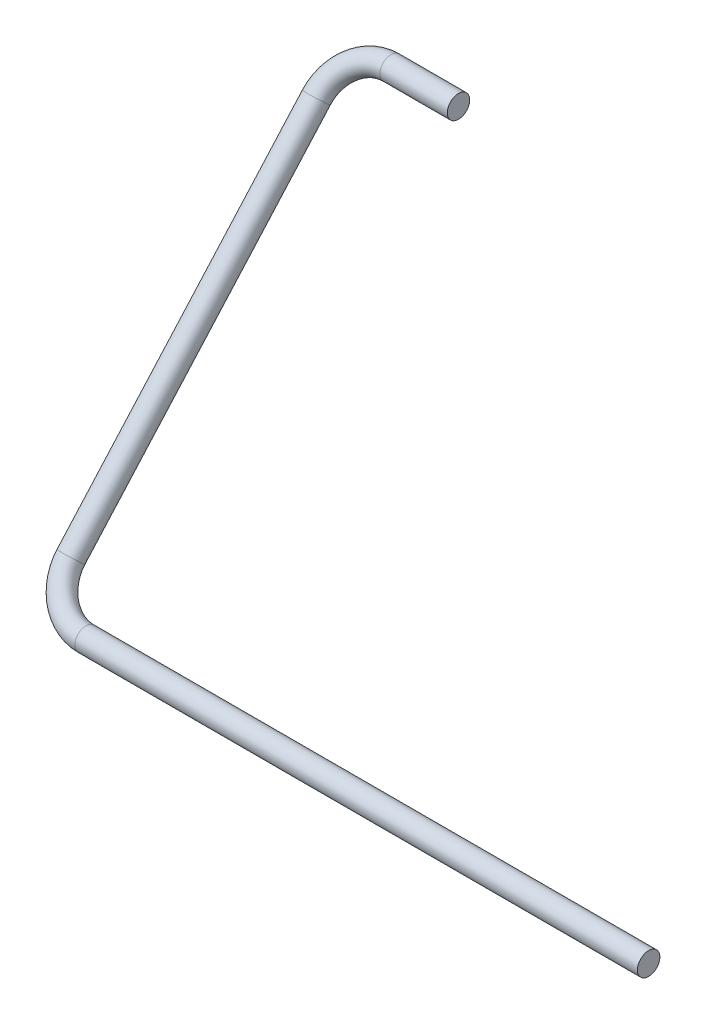
from build123d import *

# Parameters (mm, degrees)
SWEEP1_PROFILE_R = 6.35


with BuildPart() as part:
    # Sweep1: sweep along a curve in space
    with BuildLine() as sweep1_path:
        Line((-635.040454363, 1805.032599319, -106.306821176), (-673.140454363, 1805.032599319, -106.306821176))
        ThreePointArc((-673.140454363, 1805.032599319, -106.306821176), (-691.100966605, 1799.480226411, -101.355343296), (-698.540454363, 1786.075612435, -89.401418245))
        Line((-698.540454363, 1786.075612435, -89.401418245), (-698.540454363, 1630.459986884, 49.373001358))
        ThreePointArc((-673.140454363, 1611.503, 66.278404289), (-691.100966605, 1617.055372908, 61.326926409), (-698.540454363, 1630.459986884, 49.373001358))
        Line((-354.878454363, 1611.503, 66.278404289), (-673.140454363, 1611.503, 66.278404289))
    # Sweep1 profile (on start of the path) → Sweep1 (sweep)
    with BuildSketch(Plane(origin=(-635.040454363, 1805.032599319, -106.306821176), x_dir=(0, 0, -1), z_dir=(-1, 0, 0))):
        Circle(SWEEP1_PROFILE_R)
    sweep(path=sweep1_path.line)


solid = part.part
